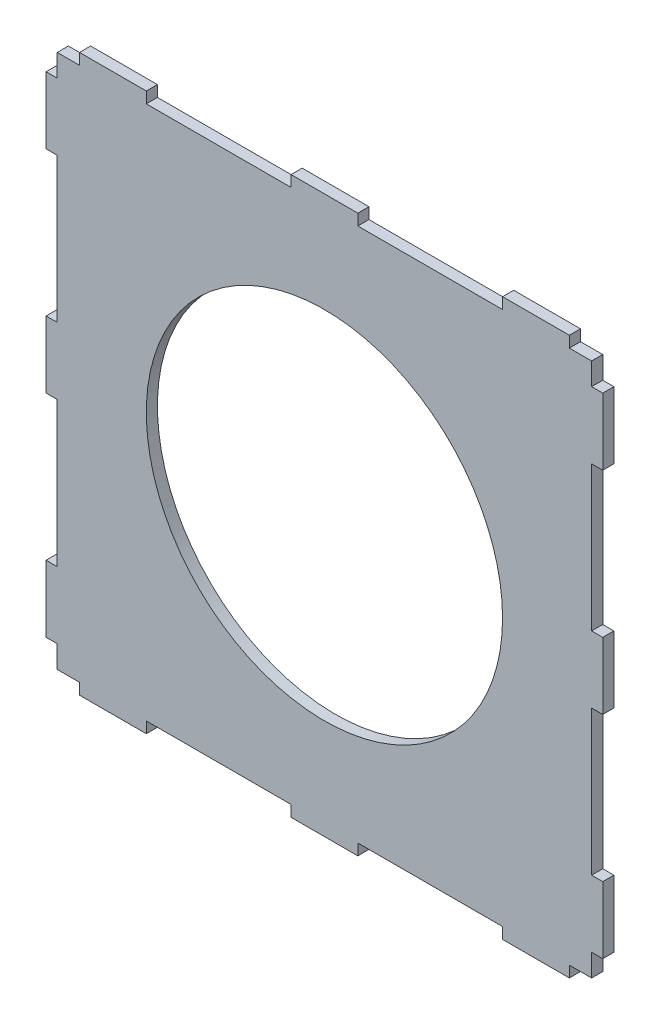
from build123d import *

# Parameters (mm, degrees)
SKETCH1_R           = 80
BOSS_EXTRUDE1_DEPTH = 5


with BuildPart() as part:
    # Sketch1 → Boss-Extrude1 (new body)
    with BuildSketch(Plane.XY):
        Polygon((-110, 120), (-120, 120), (-120, 110), (-125, 110), (-125, 80), (-120, 80), (-120, 15), (-125, 15), (-125, -15), (-120, -15), (-120, -80), (-125, -80), (-125, -110), (-120, -110), (-120, -120), (-110, -120), (-110, -125), (-80, -125), (-80, -120), (-15, -120), (-15, -125), (15, -125), (15, -120), (80, -120), (80, -125), (110, -125), (110, -120), (120, -120), (120, -110), (125, -110), (125, -80), (120, -80), (120, -15), (125, -15), (125, 15), (120, 15), (120, 80), (125, 80), (125, 110), (120, 110), (120, 120), (110, 120), (110, 125), (80, 125), (80, 120), (15, 120), (15, 125), (-15, 125), (-15, 120), (-80, 120), (-80, 125), (-110, 125), align=None)
        Circle(SKETCH1_R, mode=Mode.SUBTRACT)
    extrude(amount=BOSS_EXTRUDE1_DEPTH)


solid = part.part
